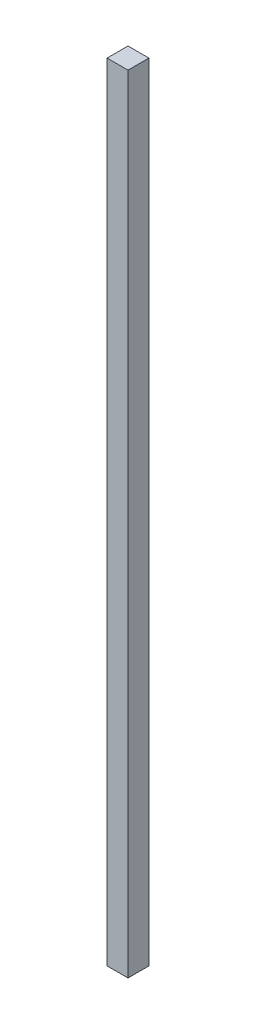
from build123d import *

# Parameters (mm, degrees)
SKETCH1_W           = 25.4
SKETCH1_H           = 25.4
BOSS_EXTRUDE1_DEPTH = 955


with BuildPart() as part:
    # Sketch1 → Boss-Extrude1 (new body)
    with BuildSketch(Plane(origin=(0, 0, 0), x_dir=(1, 0, 0), z_dir=(0, 1, 0))):
        with Locations((-27.135508984, 5.913615805)):
            Rectangle(SKETCH1_W, SKETCH1_H)
    extrude(amount=BOSS_EXTRUDE1_DEPTH)


solid = part.part
